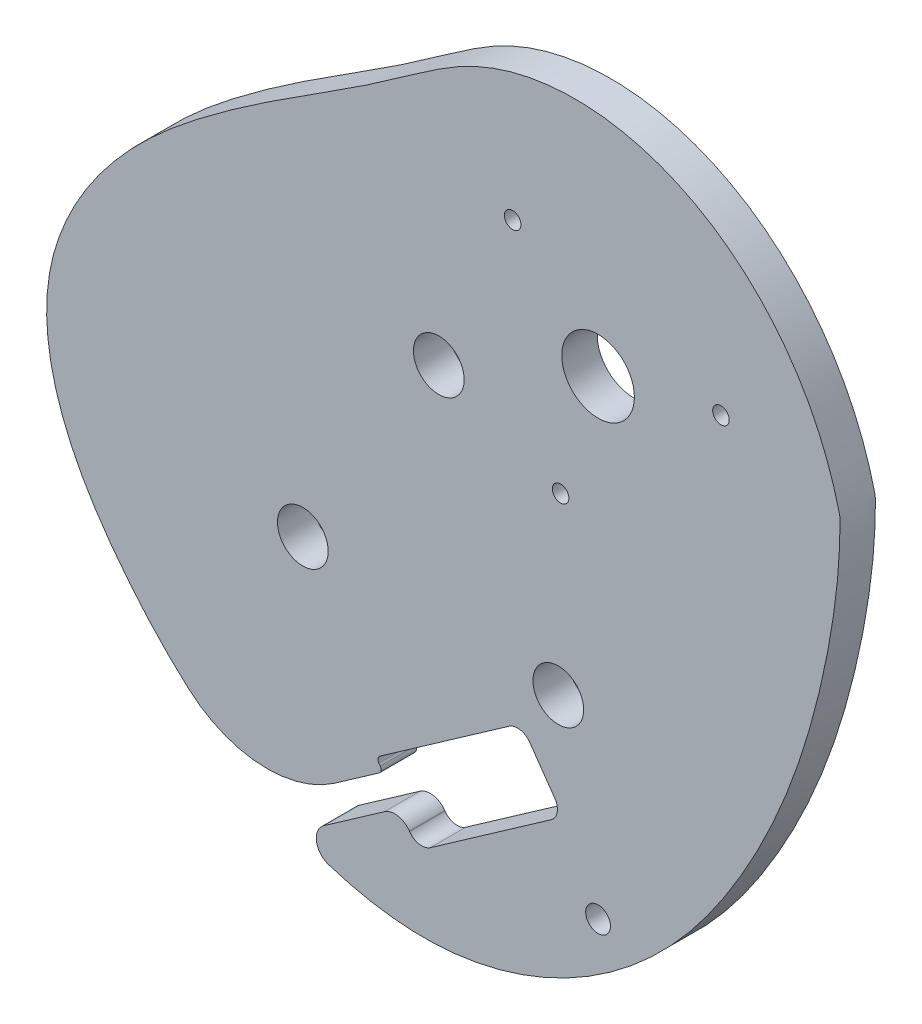
from build123d import *

# Parameters (mm, degrees)
SKETCH1_R               = 3.075
BOSS_EXTRUDE1_DEPTH     = 1.5
M4_CLEARANCE_HOLE1_D    = 4.3
CUT_EXTRUDE1_DEPTH      = 68.431915092
CUT_EXTRUDE1_DEPTH_BACK = 68.431915092
FILLET1_R               = 10
M2X0_4_TAPPED_HOLE1_D   = 1.4
FILLET2_R               = 1.5
SKETCH14_R              = 1.05
CUT_EXTRUDE2_DEPTH      = 68.431915092
FILLET3_R               = 0.4
FILLET4_R               = 1.25


with BuildPart() as part:
    # Sketch1 → Boss-Extrude1 (new, symmetric)
    with BuildSketch(Plane.XY):
        with BuildLine():
            add(Edge.make_bspline(
                [(20.469276515, 0), (20.453926982, 0.12032637), (20.37906939, 0.354674879), (20.296830063, 0.708499092), (20.201433403, 1.058274137), (20.104513169, 1.405451482), (20.003039964, 1.749648928), (19.897882185, 2.090972241), (19.788868962, 2.429397518), (19.676103633, 2.764935406), (19.559614296, 3.097587319), (19.439446847, 3.427357), (19.315640263, 3.754247363), (19.18823323, 4.078261244), (19.057262426, 4.399401123), (18.922763033, 4.717669117), (18.784768655, 5.033066908), (18.643311395, 5.345595684), (18.498421896, 5.655256084), (18.350129388, 5.962048143), (18.198461741, 6.265971239), (18.043445514, 6.567024042), (17.885106009, 6.865204466), (17.723467325, 7.160509621), (17.558552411, 7.452935769), (17.390383125, 7.742478283), (17.218980293, 8.029131604), (17.044363762, 8.312889204), (16.866552466, 8.593743551), (16.685564483, 8.871686073), (16.501417094, 9.146707128), (16.314126853, 9.418795975), (16.123709641, 9.687940747), (15.930180735, 9.954128423), (15.73355487, 10.21734481), (15.533846304, 10.477574522), (15.331068884, 10.734800958), (15.125236108, 10.989006292), (14.916361195, 11.240171456), (14.704457148, 11.48827613), (14.48953682, 11.733298735), (14.271612982, 11.975216425), (14.050698387, 12.214005082), (13.826805837, 12.449639318), (13.599948249, 12.682092471), (13.37013872, 12.911336613), (13.137390595, 13.137342549), (12.901717528, 13.360079832), (12.66313355, 13.579516764), (12.42165313, 13.795620417), (12.177291245, 14.00835664), (11.930063436, 14.21769008), (11.679985874, 14.423584196), (11.427075422, 14.626001285), (11.171349697, 14.824902501), (10.912827125, 15.020247881), (10.651527006, 15.211996372), (10.387469571, 15.400105862), (10.120676038, 15.584533205), (9.851168668, 15.765234263), (9.578970821, 15.942163933), (9.30410701, 16.115276188), (9.026602952, 16.284524115), (8.746485624, 16.449859953), (8.463783305, 16.611235142), (8.178525632, 16.768600359), (7.890743643, 16.921905569), (7.600469825, 17.071100071), (7.307738154, 17.216132546), (7.012584144, 17.356951111), (6.71504488, 17.493503366), (6.415159063, 17.625736452), (6.112967045, 17.753597106), (5.808510864, 17.877031712), (5.501834279, 17.995986365), (5.192982801, 18.110406928), (4.882003722, 18.22023909), (4.568946147, 18.32542843), (4.253861014, 18.425920478), (3.936801123, 18.521660778), (3.617821156, 18.612594954), (3.296977698, 18.698668773), (2.974329252, 18.779828214), (2.649936258, 18.856019533), (2.323861105, 18.927189329), (1.996168144, 18.993284617), (1.666923695, 19.054252892), (1.336196056, 19.110042202), (1.004055505, 19.160601215), (0.670574308, 19.205879292), (0.335826712, 19.245826554), (-0.000111049, 19.280393959), (-0.337160764, 19.309533366), (-0.675242249, 19.33319761), (-1.014273357, 19.351340575), (-1.354169986, 19.36391726), (-1.694846096, 19.370883857), (-2.036213723, 19.372197815), (-2.378182996, 19.367817918), (-2.720662158, 19.357704349), (-3.06355759, 19.341818766), (-3.406773832, 19.320124369), (-3.750213613, 19.29258597), (-4.093777879, 19.259170061), (-4.437365826, 19.219844885), (-4.780874932, 19.174580501), (-5.124200991, 19.123348854), (-5.467238158, 19.066123837), (-5.809878982, 19.002881361), (-6.152014452, 18.933599416), (-6.493534041, 18.858258136), (-6.834325754, 18.776839862), (-7.174276174, 18.689329199), (-7.513270515, 18.595713085), (-7.851192674, 18.49598084), (-8.187925289, 18.39012423), (-8.52334979, 18.278137522), (-8.857346463, 18.160017536), (-9.18979451, 18.035763705), (-9.520572102, 17.905378106), (-9.849556485, 17.76886559), (-10.176623887, 17.626233534), (-10.501650192, 17.477492989), (-10.824508724, 17.322654615), (-11.145080224, 17.161743427), (-11.463230747, 16.994735948), (-11.779050897, 16.821987195), (-12.092717082, 16.643916451), (-12.40442328, 16.460901436), (-12.714391967, 16.273307346), (-13.022869092, 16.08147821), (-13.330124311, 15.885737879), (-13.636449754, 15.686388462), (-13.942159146, 15.48370949), (-14.247586785, 15.277956924), (-14.553086511, 15.069362251), (-14.859030639, 14.858131599), (-15.165808852, 14.64444489), (-15.473827068, 14.428455032), (-15.783506277, 14.210287148), (-16.095281345, 13.990037832), (-16.40959979, 13.767774461), (-16.72692054, 13.54353453), (-17.047712658, 13.317325034), (-17.372454053, 13.089121892), (-17.701630161, 12.858869404), (-18.035732622, 12.62647976), (-18.375257928, 12.391832591), (-18.720706063, 12.15477456), (-19.072579127, 11.915119006), (-19.43137995, 11.672645633), (-19.797610697, 11.427100253), (-20.171771452, 11.17819457), (-20.554358808, 10.925606023), (-20.94586444, 10.668977684), (-21.346773666, 10.407918194), (-21.757564012, 10.14200177), (-22.178703761, 9.870768248), (-22.6106505, 9.593723189), (-23.053849668, 9.310338029), (-23.508733094, 9.020050289), (-23.975717536, 8.722263829), (-24.455203223, 8.416349151), (-24.947572399, 8.101643764), (-25.453187868, 7.777452583), (-25.972391547, 7.443048392), (-26.505503025, 7.097672347), (-27.052818136, 6.74053453), (-27.614607536, 6.370814557), (-28.191115299, 5.98766223), (-28.782557525, 5.590198235), (-29.389120965, 5.1775149), (-30.01096166, 4.74867698), (-30.64820362, 4.302722541), (-31.300937436, 3.838663708), (-31.969219271, 3.355488182), (-32.653068482, 2.852157975), (-33.352355561, 2.327705554), (-34.066325533, 1.781561053), (-34.792156176, 1.21198818), (-35.526433511, 0.617909195), (-36.265587734, -0.001457622), (-37.006020345, -0.646671842), (-37.744112291, -1.318073183), (-38.476233993, -2.015780313), (-39.198754785, -2.739691012), (-39.908052424, -3.489482365), (-40.600522516, -4.264611377), (-41.272587879, -5.064315898), (-41.920707839, -5.8876159), (-42.541387444, -6.733315094), (-43.131186577, -7.600002901), (-43.686728957, -8.486056757), (-44.204711001, -9.389644786), (-44.681910487, -10.308728765), (-45.115195144, -11.241067557), (-45.501530481, -12.184220343), (-45.837989248, -13.135551967), (-46.121753439, -14.092231719), (-46.350171981, -15.051382919), (-46.520731563, -16.010470183), (-46.635259313, -16.966833368), (-46.695881182, -17.918707922), (-46.704758414, -18.864589252), (-46.664077675, -19.803116927), (-46.576039325, -20.733069832), (-46.442852564, -21.653366621), (-46.266728948, -22.563064411), (-46.04987654, -23.461357639), (-45.794494099, -24.347576614), (-45.502765451, -25.221185937), (-45.176853985, -26.081782762), (-44.818897277, -26.929094921), (-44.431001821, -27.762978927), (-44.015237852, -28.583417844), (-43.57363427, -29.390519034), (-43.108173634, -30.184511764), (-42.620787267, -30.965744674), (-42.113350378, -31.734683158), (-41.587677508, -32.491906358), (-41.045517213, -33.238104962), (-40.488554103, -33.974069902), (-39.918413965, -34.700676565), (-39.33481729, -35.417341816), (-38.737534614, -36.123431266), (-38.126368953, -36.818284488), (-37.501156774, -37.501216811), (-36.861768424, -38.171521432), (-36.208109378, -38.828470556), (-35.54012122, -39.471316853), (-34.857782619, -40.099294871), (-34.161110261, -40.711622507), (-33.450159719, -41.307502509), (-32.725026287, -41.886124006), (-31.985845748, -42.446664075), (-31.232795105, -42.98828933), (-30.466093242, -43.510157547), (-29.686001549, -44.011419305), (-28.892824481, -44.491219662), (-28.08691006, -44.948699845), (-27.268650333, -45.382998964), (-26.438481761, -45.793255749), (-25.596885557, -46.178610297), (-24.744387965, -46.538205845), (-23.881560483, -46.871190547), (-23.009020024, -47.176719273), (-22.127429019, -47.45395541), (-21.237495463, -47.702072683), (-20.339972901, -47.920256977), (-19.435660354, -48.10770816), (-18.525402181, -48.263641942), (-17.610087896, -48.387291641), (-16.690651874, -48.477910274), (-15.768073177, -48.534771472), (-14.84337466, -48.55717479), (-13.917624463, -48.544434556), (-12.991941631, -48.495930985), (-12.067628664, -48.41094298), (-11.146068248, -48.290046351), (-10.228680944, -48.134143741), (-9.316882792, -47.944122816), (-8.412028473, -47.72093942), (-7.515412754, -47.465590968), (-6.62826823, -47.179120315), (-5.751764231, -46.862611411), (-4.88700552, -46.517187103), (-4.03503117, -46.144006323), (-3.196813506, -45.744261393), (-2.373257143, -45.319175263), (-1.565198119, -44.86999873), (-0.773403127, -44.398007635), (0.001431168, -43.904500034), (0.758678706, -43.390793354), (1.497784521, -42.858221534), (2.218265124, -42.308132156), (2.919708798, -41.74188356), (3.601775788, -41.160841961), (4.2641984, -40.566378558), (4.906780999, -39.959866645), (5.529399907, -39.342678725), (6.132003211, -38.716183626), (6.714610467, -38.081743631), (7.277312313, -37.440711615), (7.82026998, -36.794428197), (8.343714715, -36.144218914), (8.847947092, -35.491391398), (9.333336294, -34.837232621), (9.800319062, -34.183006019), (10.24939942, -33.529949158), (10.681145161, -32.879269558), (11.096195715, -32.232147378), (11.49523197, -31.589707036), (11.879149859, -30.952992781), (12.248517048, -30.322552069), (12.603694342, -29.698556098), (12.945153788, -29.0811272), (13.273344314, -28.470359529), (13.588713491, -27.866335339), (13.891701075, -27.269121707), (14.182740239, -26.678771864), (14.462256803, -26.095325337), (14.730669009, -25.518808409), (14.988387177, -24.949234509), (15.2358134, -24.386604625), (15.473341258, -23.830907716), (15.701355534, -23.282121139), (15.920231962, -22.740211075), (16.130336972, -22.205132959), (16.332027463, -21.676831916), (16.525650586, -21.155243203), (16.711543541, -20.640292652), (16.890033391, -20.131897115), (17.061436892, -19.629964916), (17.226060335, -19.134396296), (17.384199405, -18.645083873), (17.536139055, -18.161913089), (17.682153396, -17.684762669), (17.822505599, -17.213505075), (17.957447815, -16.748006957), (18.087221108, -16.288129613), (18.212055405, -15.833729436), (18.332169455, -15.384658369), (18.447770812, -14.940764355), (18.559055824, -14.501891782), (18.666209639, -14.067881928), (18.769406229, -13.638573405), (18.868808423, -13.213802595), (18.964567955, -12.793404083), (19.056825528, -12.37721109), (19.14571089, -11.965055896), (19.231342923, -11.556770257), (19.313829749, -11.152185827), (19.393268841, -10.751134561), (19.469747157, -10.353449118), (19.543341277, -9.95896326), (19.614117561, -9.567512236), (19.682132311, -9.178933172), (19.747431952, -8.793065437), (19.810053221, -8.409751015), (19.870023364, -8.028834861), (19.927360353, -7.650165254), (19.982073105, -7.273594135), (20.034161718, -6.898977439), (20.083617711, -6.526175422), (20.130424277, -6.15505297), (20.174556549, -5.785479904), (20.215981868, -5.417331275), (20.254660065, -5.050487643), (20.290543747, -4.684835353), (20.323578606, -4.320266795), (20.353703685, -3.956680655), (20.380851823, -3.593982143), (20.404949486, -3.232083278), (20.425918912, -2.87090287), (20.443671673, -2.510367615), (20.458134208, -2.150408957), (20.469154396, -1.790975662), (20.476850973, -1.431987855), (20.480314085, -1.073508931), (20.482447125, -0.715105964), (20.47192834, -0.358233383), (20.484273463, -0.11756243), (20.469276515, 0)],
                knots=[0, 0, 0, 0, 0.001764203, 0.003519492, 0.005266096, 0.007004244, 0.008734164, 0.010456082, 0.01217022, 0.013876802, 0.015576046, 0.017268173, 0.018953398, 0.020631935, 0.022303998, 0.023969797, 0.025629542, 0.027283438, 0.02893169, 0.030574501, 0.032212071, 0.033844598, 0.035472279, 0.037095307, 0.038713875, 0.04032817, 0.041938381, 0.043544692, 0.045147285, 0.046746342, 0.048342038, 0.04993455, 0.05152405, 0.053110709, 0.054694695, 0.056276173, 0.057855307, 0.059432256, 0.061007179, 0.062580232, 0.064151567, 0.065721335, 0.067289683, 0.068856757, 0.070422701, 0.071987653, 0.073551752, 0.075115133, 0.076677929, 0.078240269, 0.079802281, 0.08136409, 0.082925818, 0.084487586, 0.08604951, 0.087611705, 0.089174283, 0.090737355, 0.092301027, 0.093865405, 0.09543059, 0.096996683, 0.09856378, 0.100131977, 0.101701366, 0.103272038, 0.10484408, 0.106417578, 0.107992614, 0.109569269, 0.111147622, 0.112727748, 0.114309722, 0.115893614, 0.117479494, 0.11906743, 0.120657485, 0.122249722, 0.123844203, 0.125440984, 0.127040123, 0.128641672, 0.130245685, 0.13185221, 0.133461296, 0.135072989, 0.136687331, 0.138304365, 0.139924131, 0.141546665, 0.143172005, 0.144800184, 0.146431233, 0.148065183, 0.149702063, 0.151341898, 0.152984714, 0.154630532, 0.156279374, 0.157931258, 0.159586203, 0.161244224, 0.162905335, 0.164569548, 0.166236874, 0.167907321, 0.169580897, 0.171257607, 0.172937454, 0.174620442, 0.176306572, 0.177995841, 0.179688248, 0.181383788, 0.183082456, 0.184784246, 0.186489147, 0.188197151, 0.189908245, 0.191622417, 0.193339652, 0.195059933, 0.196783244, 0.198509566, 0.200238878, 0.201971181, 0.203706635, 0.205445504, 0.2071881, 0.208934793, 0.210686019, 0.212442285, 0.214204179, 0.215972379, 0.217747655, 0.219530879, 0.221323028, 0.223125194, 0.224938584, 0.226764524, 0.228604465, 0.230459983, 0.232332781, 0.234224685, 0.236137652, 0.238073757, 0.2400352, 0.242024293, 0.244043462, 0.246095238, 0.248182252, 0.250307226, 0.252472967, 0.254682362, 0.256938364, 0.259243991, 0.261602312, 0.264016447, 0.266489554, 0.269024826, 0.271625481, 0.274294763, 0.277035933, 0.279852264, 0.282747038, 0.285723547, 0.288785083, 0.291934943, 0.295176421, 0.298512813, 0.30194741, 0.305483503, 0.309124377, 0.312873317, 0.316733603, 0.320708513, 0.324801324, 0.329015309, 0.333351662, 0.33780314, 0.342360129, 0.347012767, 0.351751024, 0.35656476, 0.361443788, 0.366377916, 0.371356998, 0.376370977, 0.381409928, 0.386464106, 0.391523993, 0.396580347, 0.401624264, 0.406647238, 0.411641236, 0.416598779, 0.421513038, 0.426377942, 0.431188305, 0.435939966, 0.440631828, 0.445270717, 0.449864684, 0.454421044, 0.458946377, 0.463446541, 0.467926691, 0.472391308, 0.476844238, 0.481288728, 0.48572748, 0.490162693, 0.494596121, 0.499029126, 0.50346273, 0.507897674, 0.512334472, 0.516773466, 0.521214882, 0.525658883, 0.530105625, 0.534555313, 0.539008153, 0.543464074, 0.5479229, 0.552384417, 0.556848379, 0.561314515, 0.565782528, 0.570252105, 0.57472292, 0.579194639, 0.583666924, 0.588139439, 0.592611855, 0.597083853, 0.601555132, 0.606025412, 0.610494439, 0.614961992, 0.619427887, 0.623891985, 0.628354194, 0.632814475, 0.637272853, 0.641729416, 0.646184326, 0.650637823, 0.655090233, 0.659541971, 0.663993554, 0.668445597, 0.672898832, 0.677354104, 0.681812384, 0.68627477, 0.690742499, 0.695216754, 0.699697325, 0.704183213, 0.708673274, 0.713166232, 0.71766069, 0.722155137, 0.726647962, 0.731137456, 0.735621826, 0.7400992, 0.744567632, 0.749025113, 0.753469575, 0.757898896, 0.762310907, 0.766703399, 0.771074124, 0.775420805, 0.779741136, 0.784032793, 0.788293433, 0.792520702, 0.796712241, 0.800865688, 0.804978687, 0.809048891, 0.813073968, 0.817051612, 0.820979544, 0.824855525, 0.82867736, 0.832442913, 0.836150111, 0.839796963, 0.843381676, 0.84690413, 0.850365453, 0.853766802, 0.857109335, 0.860394205, 0.863622561, 0.866795554, 0.86991433, 0.872980033, 0.875993807, 0.878956793, 0.881870128, 0.88473495, 0.887552392, 0.890323587, 0.893049665, 0.895731754, 0.898370977, 0.900968457, 0.903525314, 0.906042661, 0.908521612, 0.910963275, 0.913368751, 0.915739141, 0.918075538, 0.920379029, 0.922650695, 0.924891611, 0.927102843, 0.929285451, 0.931440483, 0.93356898, 0.935671971, 0.937750475, 0.939805498, 0.941838034, 0.943849063, 0.945839551, 0.947810449, 0.949762689, 0.95169719, 0.953614851, 0.955516554, 0.957403159, 0.959275508, 0.961134423, 0.962980703, 0.964815124, 0.966638443, 0.96845139, 0.970254675, 0.972048981, 0.973834969, 0.975613274, 0.977384508, 0.979149256, 0.980908081, 0.982661518, 0.984410078, 0.98615425, 0.987894493, 0.989631248, 0.991364926, 0.993095918, 0.994824589, 0.996551283, 0.998276321, 1, 1, 1, 1], degree=3))
        make_face()
        Circle(SKETCH1_R, mode=Mode.SUBTRACT)
    extrude(amount=BOSS_EXTRUDE1_DEPTH, both=True)

    # M4 Clearance Hole1 (through all)
    with Locations(Plane.XY.offset(1.5)):
        with Locations((-13.488047982, -5.9360377), (-3.367538379, -25.076378767), (-25.003814781, -24.270826649)):
            Hole(M4_CLEARANCE_HOLE1_D / 2)

    # Sketch8 → Cut-Extrude1 (cut, two sides)
    with BuildSketch(Plane.XY.offset(1.5)) as cut_extrude1_sk:
        Polygon((-28.446199298, -45.301892696), (-27.069615851, -47.267857602), (-16.845389985, -40.108777579), (-15.239375963, -42.402403303), (-3.361671321, -34.085544975), (-2.952095299, -33.798756757), (-6.508269204, -28.720014083), (-6.917845227, -29.006802301), (-18.795549869, -37.323660628), (-18.221973432, -38.142812672), align=None)
    extrude(amount=CUT_EXTRUDE1_DEPTH, mode=Mode.SUBTRACT)
    extrude(cut_extrude1_sk.sketch, amount=-CUT_EXTRUDE1_DEPTH_BACK, mode=Mode.SUBTRACT)

    # Fillet1
    fillet1_edges = [part.edges().sort_by_distance(p)[0] for p in [
        (-28.001446815, -44.990473655, 0.7499997),
    ]]
    fillet(fillet1_edges, radius=FILLET1_R)

    # M2x0.4 Tapped Hole1 (through all)
    with Locations(Plane(origin=(0, 0, -1.5), x_dir=(-1, 0, 0), z_dir=(0, 0, -1))):
        with Locations((7.233951111, 7.840674418), (-10.407198784, 2.344448223), (3.173247673, -10.185122641)):
            Hole(M2X0_4_TAPPED_HOLE1_D / 2)

    # Fillet2
    fillet2_edges = [part.edges().sort_by_distance(p)[0] for p in [
        (-25.541458366, -46.197830211, 0.7499997),
        (-16.845389985, -40.108777579, 0),
    ]]
    fillet(fillet2_edges, radius=FILLET2_R)

    # Sketch14 → Cut-Extrude2 (cut, through all)
    with BuildSketch(Plane.XY.offset(1.5)):
        with Locations((0, -39.8190457)):
            Circle(SKETCH14_R)
    extrude(amount=-CUT_EXTRUDE2_DEPTH, mode=Mode.SUBTRACT)

    # Fillet3
    fillet3_edges = [part.edges().sort_by_distance(p)[0] for p in [
        (-18.221973432, -38.142812672, 0),
        (-18.795549869, -37.323660628, 0),
    ]]
    fillet(fillet3_edges, radius=FILLET3_R)

    # Fillet4
    fillet4_edges = [part.edges().sort_by_distance(p)[0] for p in [
        (-6.508269204, -28.720014083, 0),
        (-2.952095299, -33.798756757, 0),
        (-15.239375963, -42.402403303, 0),
    ]]
    fillet(fillet4_edges, radius=FILLET4_R)


solid = part.part
